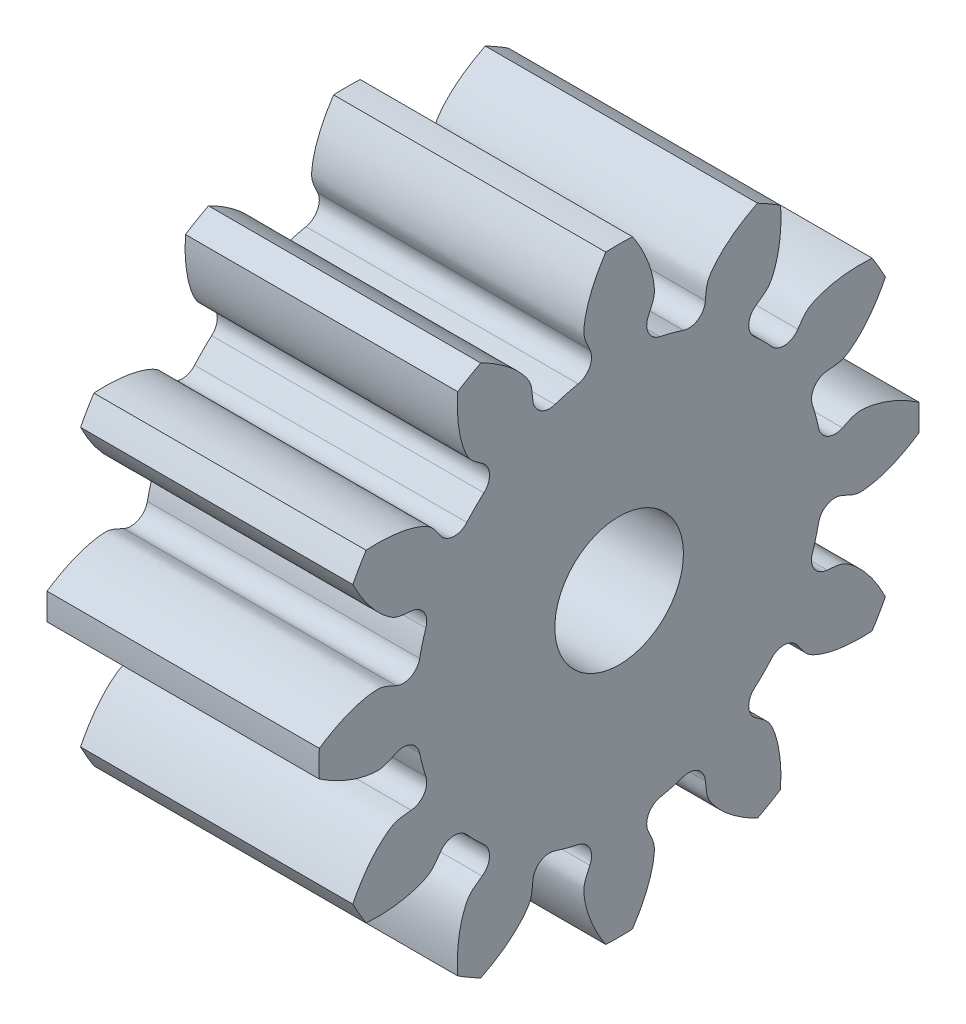
from build123d import *

# Parameters (mm, degrees)
EXTRUDE1_DEPTH      = 3.175
EXTRUDE1_DEPTH_BACK = 3.175
SKETCH2_R           = 1.5
CUT_EXTRUDE1_DEPTH  = 6.35


with BuildPart() as part:
    # Sketch1 → Extrude1 (new body, two sides)
    with BuildSketch(Plane(origin=(0, 0, 0), x_dir=(0, 0, -1), z_dir=(1, 0, 0))) as extrude1_sk:
        with BuildLine():
            ThreePointArc((-0.310347402, -6.993116937), (0, -7), (0.310347402, -6.993116937))
            add(Edge.make_bspline(
                [(0.310347402, -6.993116937), (0.332454088, -6.960100751), (0.397086112, -6.860495296), (0.507596749, -6.672467535), (0.626125065, -6.431893946), (0.720246921, -6.186920197), (0.779000049, -5.979736241), (0.809954136, -5.81518889), (0.821047695, -5.703074132), (0.822305692, -5.636998123), (0.821610044, -5.605303583), (0.814736989, -5.520886657), (0.783208617, -5.41000535), (0.683474653, -5.206966814)],
                knots=[0.012881598, 0.012881598, 0.012881598, 0.012881598, 0.092763794, 0.252528185, 0.452803648, 0.613451009, 0.736634468, 0.825277424, 0.882733012, 0.901221839, 0.913572897, 0.922587449, 0.997832853, 0.997832853, 0.997832853, 0.997832853], degree=3, weights=[1, 1, 1, 1, 1, 1, 1, 1, 1, 1, 1, 1, 1, 1]))
            ThreePointArc((0.683474653, -5.206966814), (0.6833523, -4.863322946), (0.955104633, -4.652985616))
            ThreePointArc((0.955104633, -4.652985616), (1.229390464, -4.588147675), (1.499347932, -4.507156063))
            ThreePointArc((1.499347932, -4.507156063), (1.839861021, -4.553437368), (2.011576994, -4.851102864))
            add(Edge.make_bspline(
                [(2.011576994, -4.851102864), (2.026724117, -5.076806376), (2.054860398, -5.188596591), (2.091116621, -5.265140321), (2.106361443, -5.292936422), (2.140488904, -5.349530925), (2.206153588, -5.441078375), (2.315234289, -5.568103517), (2.469707968, -5.718153522), (2.67370676, -5.883246084), (2.896642088, -6.032324766), (3.086360987, -6.139906265), (3.19213669, -6.193851107), (3.227789734, -6.21139062)],
                knots=[0.002100409, 0.002100409, 0.002100409, 0.002100409, 0.077349591, 0.086364597, 0.098716275, 0.11720603, 0.174664504, 0.263311911, 0.386501556, 0.547156985, 0.747442506, 0.90721492, 0.987101128, 0.987101128, 0.987101128, 0.987101128], degree=3, weights=[1, 1, 1, 1, 1, 1, 1, 1, 1, 1, 1, 1, 1, 1]))
            ThreePointArc((3.227789734, -6.21139062), (3.5, -6.062177826), (3.765327202, -5.901043218))
            add(Edge.make_bspline(
                [(3.765327202, -5.901043218), (3.767964061, -5.861397019), (3.774134309, -5.742820152), (3.775825447, -5.524728017), (3.758187185, -5.257121019), (3.717212229, -4.997906601), (3.664501952, -4.789103468), (3.609035303, -4.631124239), (3.562585227, -4.52848323), (3.530636681, -4.47063073), (3.514186962, -4.443530277), (3.466026259, -4.373859602), (3.383281234, -4.293597759), (3.195389819, -4.167628211)],
                knots=[0.012881598, 0.012881598, 0.012881598, 0.012881598, 0.092763794, 0.252528185, 0.452803648, 0.613451009, 0.736634468, 0.825277424, 0.882733012, 0.901221839, 0.913572897, 0.922587449, 0.997832853, 0.997832853, 0.997832853, 0.997832853], degree=3, weights=[1, 1, 1, 1, 1, 1, 1, 1, 1, 1, 1, 1, 1, 1]))
            ThreePointArc((3.195389819, -4.167628211), (3.023461924, -3.870085068), (3.153637683, -3.55205143))
            ThreePointArc((3.153637683, -3.55205143), (3.358757211, -3.358757211), (3.55205143, -3.153637683))
            ThreePointArc((3.55205143, -3.153637683), (3.870085068, -3.023461924), (4.167628211, -3.195389819))
            add(Edge.make_bspline(
                [(4.167628211, -3.195389819), (4.293597759, -3.383281234), (4.373859602, -3.466026259), (4.443530277, -3.514186962), (4.47063073, -3.530636681), (4.52848323, -3.562585227), (4.631124239, -3.609035303), (4.789103468, -3.664501952), (4.997906601, -3.717212229), (5.257121019, -3.758187185), (5.524728017, -3.775825447), (5.742820152, -3.774134309), (5.861397019, -3.767964061), (5.901043218, -3.765327202)],
                knots=[0.002100409, 0.002100409, 0.002100409, 0.002100409, 0.077349591, 0.086364597, 0.098716275, 0.11720603, 0.174664504, 0.263311911, 0.386501556, 0.547156985, 0.747442506, 0.90721492, 0.987101128, 0.987101128, 0.987101128, 0.987101128], degree=3, weights=[1, 1, 1, 1, 1, 1, 1, 1, 1, 1, 1, 1, 1, 1]))
            ThreePointArc((5.901043218, -3.765327202), (6.062177826, -3.5), (6.21139062, -3.227789734))
            add(Edge.make_bspline(
                [(6.21139062, -3.227789734), (6.193851107, -3.19213669), (6.139906265, -3.086360987), (6.032324766, -2.896642088), (5.883246084, -2.67370676), (5.718153522, -2.469707968), (5.568103517, -2.315234289), (5.441078375, -2.206153588), (5.349530925, -2.140488904), (5.292936422, -2.106361443), (5.265140321, -2.091116621), (5.188596591, -2.054860398), (5.076806376, -2.026724117), (4.851102864, -2.011576994)],
                knots=[0.012881598, 0.012881598, 0.012881598, 0.012881598, 0.092763794, 0.252528185, 0.452803648, 0.613451009, 0.736634468, 0.825277424, 0.882733012, 0.901221839, 0.913572897, 0.922587449, 0.997832853, 0.997832853, 0.997832853, 0.997832853], degree=3, weights=[1, 1, 1, 1, 1, 1, 1, 1, 1, 1, 1, 1, 1, 1]))
            ThreePointArc((4.851102864, -2.011576994), (4.553437368, -1.839861021), (4.507156063, -1.499347932))
            ThreePointArc((4.507156063, -1.499347932), (4.588147675, -1.229390464), (4.652985616, -0.955104633))
            ThreePointArc((4.652985616, -0.955104633), (4.863322946, -0.6833523), (5.206966814, -0.683474653))
            add(Edge.make_bspline(
                [(5.206966814, -0.683474653), (5.41000535, -0.783208617), (5.520886657, -0.814736989), (5.605303583, -0.821610044), (5.636998123, -0.822305692), (5.703074132, -0.821047695), (5.81518889, -0.809954136), (5.979736241, -0.779000049), (6.186920197, -0.720246921), (6.431893946, -0.626125065), (6.672467535, -0.507596749), (6.860495296, -0.397086112), (6.960100751, -0.332454088), (6.993116937, -0.310347402)],
                knots=[0.002100409, 0.002100409, 0.002100409, 0.002100409, 0.077349591, 0.086364597, 0.098716275, 0.11720603, 0.174664504, 0.263311911, 0.386501556, 0.547156985, 0.747442506, 0.90721492, 0.987101128, 0.987101128, 0.987101128, 0.987101128], degree=3, weights=[1, 1, 1, 1, 1, 1, 1, 1, 1, 1, 1, 1, 1, 1]))
            ThreePointArc((6.993116937, -0.310347402), (7, 0), (6.993116937, 0.310347402))
            add(Edge.make_bspline(
                [(6.993116937, 0.310347402), (6.960100751, 0.332454088), (6.860495296, 0.397086112), (6.672467535, 0.507596749), (6.431893946, 0.626125065), (6.186920197, 0.720246921), (5.979736241, 0.779000049), (5.81518889, 0.809954136), (5.703074132, 0.821047695), (5.636998123, 0.822305692), (5.605303583, 0.821610044), (5.520886657, 0.814736989), (5.41000535, 0.783208617), (5.206966814, 0.683474653)],
                knots=[0.012881598, 0.012881598, 0.012881598, 0.012881598, 0.092763794, 0.252528185, 0.452803648, 0.613451009, 0.736634468, 0.825277424, 0.882733012, 0.901221839, 0.913572897, 0.922587449, 0.997832853, 0.997832853, 0.997832853, 0.997832853], degree=3, weights=[1, 1, 1, 1, 1, 1, 1, 1, 1, 1, 1, 1, 1, 1]))
            ThreePointArc((5.206966814, 0.683474653), (4.863322946, 0.6833523), (4.652985616, 0.955104633))
            ThreePointArc((4.652985616, 0.955104633), (4.588147675, 1.229390464), (4.507156063, 1.499347932))
            ThreePointArc((4.507156063, 1.499347932), (4.553437368, 1.839861021), (4.851102864, 2.011576994))
            add(Edge.make_bspline(
                [(4.851102864, 2.011576994), (5.076806376, 2.026724117), (5.188596591, 2.054860398), (5.265140321, 2.091116621), (5.292936422, 2.106361443), (5.349530925, 2.140488904), (5.441078375, 2.206153588), (5.568103517, 2.315234289), (5.718153522, 2.469707968), (5.883246084, 2.67370676), (6.032324766, 2.896642088), (6.139906265, 3.086360987), (6.193851107, 3.19213669), (6.21139062, 3.227789734)],
                knots=[0.002100409, 0.002100409, 0.002100409, 0.002100409, 0.077349591, 0.086364597, 0.098716275, 0.11720603, 0.174664504, 0.263311911, 0.386501556, 0.547156985, 0.747442506, 0.90721492, 0.987101128, 0.987101128, 0.987101128, 0.987101128], degree=3, weights=[1, 1, 1, 1, 1, 1, 1, 1, 1, 1, 1, 1, 1, 1]))
            ThreePointArc((6.21139062, 3.227789734), (6.062177826, 3.5), (5.901043218, 3.765327202))
            add(Edge.make_bspline(
                [(5.901043218, 3.765327202), (5.861397019, 3.767964061), (5.742820152, 3.774134309), (5.524728017, 3.775825447), (5.257121019, 3.758187185), (4.997906601, 3.717212229), (4.789103468, 3.664501952), (4.631124239, 3.609035303), (4.52848323, 3.562585227), (4.47063073, 3.530636681), (4.443530277, 3.514186962), (4.373859602, 3.466026259), (4.293597759, 3.383281234), (4.167628211, 3.195389819)],
                knots=[0.012881598, 0.012881598, 0.012881598, 0.012881598, 0.092763794, 0.252528185, 0.452803648, 0.613451009, 0.736634468, 0.825277424, 0.882733012, 0.901221839, 0.913572897, 0.922587449, 0.997832853, 0.997832853, 0.997832853, 0.997832853], degree=3, weights=[1, 1, 1, 1, 1, 1, 1, 1, 1, 1, 1, 1, 1, 1]))
            ThreePointArc((4.167628211, 3.195389819), (3.870085068, 3.023461924), (3.55205143, 3.153637683))
            ThreePointArc((3.55205143, 3.153637683), (3.358757211, 3.358757211), (3.153637683, 3.55205143))
            ThreePointArc((3.153637683, 3.55205143), (3.023461924, 3.870085068), (3.195389819, 4.167628211))
            add(Edge.make_bspline(
                [(3.195389819, 4.167628211), (3.383281234, 4.293597759), (3.466026259, 4.373859602), (3.514186962, 4.443530277), (3.530636681, 4.47063073), (3.562585227, 4.52848323), (3.609035303, 4.631124239), (3.664501952, 4.789103468), (3.717212229, 4.997906601), (3.758187185, 5.257121019), (3.775825447, 5.524728017), (3.774134309, 5.742820152), (3.767964061, 5.861397019), (3.765327202, 5.901043218)],
                knots=[0.002100409, 0.002100409, 0.002100409, 0.002100409, 0.077349591, 0.086364597, 0.098716275, 0.11720603, 0.174664504, 0.263311911, 0.386501556, 0.547156985, 0.747442506, 0.90721492, 0.987101128, 0.987101128, 0.987101128, 0.987101128], degree=3, weights=[1, 1, 1, 1, 1, 1, 1, 1, 1, 1, 1, 1, 1, 1]))
            ThreePointArc((3.765327202, 5.901043218), (3.5, 6.062177826), (3.227789734, 6.21139062))
            add(Edge.make_bspline(
                [(3.227789734, 6.21139062), (3.19213669, 6.193851107), (3.086360987, 6.139906265), (2.896642088, 6.032324766), (2.67370676, 5.883246084), (2.469707968, 5.718153522), (2.315234289, 5.568103517), (2.206153588, 5.441078375), (2.140488904, 5.349530925), (2.106361443, 5.292936422), (2.091116621, 5.265140321), (2.054860398, 5.188596591), (2.026724117, 5.076806376), (2.011576994, 4.851102864)],
                knots=[0.012881598, 0.012881598, 0.012881598, 0.012881598, 0.092763794, 0.252528185, 0.452803648, 0.613451009, 0.736634468, 0.825277424, 0.882733012, 0.901221839, 0.913572897, 0.922587449, 0.997832853, 0.997832853, 0.997832853, 0.997832853], degree=3, weights=[1, 1, 1, 1, 1, 1, 1, 1, 1, 1, 1, 1, 1, 1]))
            ThreePointArc((2.011576994, 4.851102864), (1.839861021, 4.553437368), (1.499347932, 4.507156063))
            ThreePointArc((1.499347932, 4.507156063), (1.229390464, 4.588147675), (0.955104633, 4.652985616))
            ThreePointArc((0.955104633, 4.652985616), (0.6833523, 4.863322946), (0.683474653, 5.206966814))
            add(Edge.make_bspline(
                [(0.683474653, 5.206966814), (0.783208617, 5.41000535), (0.814736989, 5.520886657), (0.821610044, 5.605303583), (0.822305692, 5.636998123), (0.821047695, 5.703074132), (0.809954136, 5.81518889), (0.779000049, 5.979736241), (0.720246921, 6.186920197), (0.626125065, 6.431893946), (0.507596749, 6.672467535), (0.397086112, 6.860495296), (0.332454088, 6.960100751), (0.310347402, 6.993116937)],
                knots=[0.002100409, 0.002100409, 0.002100409, 0.002100409, 0.077349591, 0.086364597, 0.098716275, 0.11720603, 0.174664504, 0.263311911, 0.386501556, 0.547156985, 0.747442506, 0.90721492, 0.987101128, 0.987101128, 0.987101128, 0.987101128], degree=3, weights=[1, 1, 1, 1, 1, 1, 1, 1, 1, 1, 1, 1, 1, 1]))
            ThreePointArc((0.310347402, 6.993116937), (0, 7), (-0.310347402, 6.993116937))
            add(Edge.make_bspline(
                [(-0.310347402, 6.993116937), (-0.332454088, 6.960100751), (-0.397086112, 6.860495296), (-0.507596749, 6.672467535), (-0.626125065, 6.431893946), (-0.720246921, 6.186920197), (-0.779000049, 5.979736241), (-0.809954136, 5.81518889), (-0.821047695, 5.703074132), (-0.822305692, 5.636998123), (-0.821610044, 5.605303583), (-0.814736989, 5.520886657), (-0.783208617, 5.41000535), (-0.683474653, 5.206966814)],
                knots=[0.012881598, 0.012881598, 0.012881598, 0.012881598, 0.092763794, 0.252528185, 0.452803648, 0.613451009, 0.736634468, 0.825277424, 0.882733012, 0.901221839, 0.913572897, 0.922587449, 0.997832853, 0.997832853, 0.997832853, 0.997832853], degree=3, weights=[1, 1, 1, 1, 1, 1, 1, 1, 1, 1, 1, 1, 1, 1]))
            ThreePointArc((-0.683474653, 5.206966814), (-0.6833523, 4.863322946), (-0.955104633, 4.652985616))
            ThreePointArc((-0.955104633, 4.652985616), (-1.229390464, 4.588147675), (-1.499347932, 4.507156063))
            ThreePointArc((-1.499347932, 4.507156063), (-1.839861021, 4.553437368), (-2.011576994, 4.851102864))
            add(Edge.make_bspline(
                [(-2.011576994, 4.851102864), (-2.026724117, 5.076806376), (-2.054860398, 5.188596591), (-2.091116621, 5.265140321), (-2.106361443, 5.292936422), (-2.140488904, 5.349530925), (-2.206153588, 5.441078375), (-2.315234289, 5.568103517), (-2.469707968, 5.718153522), (-2.67370676, 5.883246084), (-2.896642088, 6.032324766), (-3.086360987, 6.139906265), (-3.19213669, 6.193851107), (-3.227789734, 6.21139062)],
                knots=[0.002100409, 0.002100409, 0.002100409, 0.002100409, 0.077349591, 0.086364597, 0.098716275, 0.11720603, 0.174664504, 0.263311911, 0.386501556, 0.547156985, 0.747442506, 0.90721492, 0.987101128, 0.987101128, 0.987101128, 0.987101128], degree=3, weights=[1, 1, 1, 1, 1, 1, 1, 1, 1, 1, 1, 1, 1, 1]))
            ThreePointArc((-3.227789734, 6.21139062), (-3.5, 6.062177826), (-3.765327202, 5.901043218))
            add(Edge.make_bspline(
                [(-3.765327202, 5.901043218), (-3.767964061, 5.861397019), (-3.774134309, 5.742820152), (-3.775825447, 5.524728017), (-3.758187185, 5.257121019), (-3.717212229, 4.997906601), (-3.664501952, 4.789103468), (-3.609035303, 4.631124239), (-3.562585227, 4.52848323), (-3.530636681, 4.47063073), (-3.514186962, 4.443530277), (-3.466026259, 4.373859602), (-3.383281234, 4.293597759), (-3.195389819, 4.167628211)],
                knots=[0.012881598, 0.012881598, 0.012881598, 0.012881598, 0.092763794, 0.252528185, 0.452803648, 0.613451009, 0.736634468, 0.825277424, 0.882733012, 0.901221839, 0.913572897, 0.922587449, 0.997832853, 0.997832853, 0.997832853, 0.997832853], degree=3, weights=[1, 1, 1, 1, 1, 1, 1, 1, 1, 1, 1, 1, 1, 1]))
            ThreePointArc((-3.195389819, 4.167628211), (-3.023461924, 3.870085068), (-3.153637683, 3.55205143))
            ThreePointArc((-3.153637683, 3.55205143), (-3.358757211, 3.358757211), (-3.55205143, 3.153637683))
            ThreePointArc((-3.55205143, 3.153637683), (-3.870085068, 3.023461924), (-4.167628211, 3.195389819))
            add(Edge.make_bspline(
                [(-4.167628211, 3.195389819), (-4.293597759, 3.383281234), (-4.373859602, 3.466026259), (-4.443530277, 3.514186962), (-4.47063073, 3.530636681), (-4.52848323, 3.562585227), (-4.631124239, 3.609035303), (-4.789103468, 3.664501952), (-4.997906601, 3.717212229), (-5.257121019, 3.758187185), (-5.524728017, 3.775825447), (-5.742820152, 3.774134309), (-5.861397019, 3.767964061), (-5.901043218, 3.765327202)],
                knots=[0.002100409, 0.002100409, 0.002100409, 0.002100409, 0.077349591, 0.086364597, 0.098716275, 0.11720603, 0.174664504, 0.263311911, 0.386501556, 0.547156985, 0.747442506, 0.90721492, 0.987101128, 0.987101128, 0.987101128, 0.987101128], degree=3, weights=[1, 1, 1, 1, 1, 1, 1, 1, 1, 1, 1, 1, 1, 1]))
            ThreePointArc((-5.901043218, 3.765327202), (-6.062177826, 3.5), (-6.21139062, 3.227789734))
            add(Edge.make_bspline(
                [(-6.21139062, 3.227789734), (-6.193851107, 3.19213669), (-6.139906265, 3.086360987), (-6.032324766, 2.896642088), (-5.883246084, 2.67370676), (-5.718153522, 2.469707968), (-5.568103517, 2.315234289), (-5.441078375, 2.206153588), (-5.349530925, 2.140488904), (-5.292936422, 2.106361443), (-5.265140321, 2.091116621), (-5.188596591, 2.054860398), (-5.076806376, 2.026724117), (-4.851102864, 2.011576994)],
                knots=[0.012881598, 0.012881598, 0.012881598, 0.012881598, 0.092763794, 0.252528185, 0.452803648, 0.613451009, 0.736634468, 0.825277424, 0.882733012, 0.901221839, 0.913572897, 0.922587449, 0.997832853, 0.997832853, 0.997832853, 0.997832853], degree=3, weights=[1, 1, 1, 1, 1, 1, 1, 1, 1, 1, 1, 1, 1, 1]))
            ThreePointArc((-4.851102864, 2.011576994), (-4.553437368, 1.839861021), (-4.507156063, 1.499347932))
            ThreePointArc((-4.507156063, 1.499347932), (-4.588147675, 1.229390464), (-4.652985616, 0.955104633))
            ThreePointArc((-4.652985616, 0.955104633), (-4.863322946, 0.6833523), (-5.206966814, 0.683474653))
            add(Edge.make_bspline(
                [(-5.206966814, 0.683474653), (-5.41000535, 0.783208617), (-5.520886657, 0.814736989), (-5.605303583, 0.821610044), (-5.636998123, 0.822305692), (-5.703074132, 0.821047695), (-5.81518889, 0.809954136), (-5.979736241, 0.779000049), (-6.186920197, 0.720246921), (-6.431893946, 0.626125065), (-6.672467535, 0.507596749), (-6.860495296, 0.397086112), (-6.960100751, 0.332454088), (-6.993116937, 0.310347402)],
                knots=[0.002100409, 0.002100409, 0.002100409, 0.002100409, 0.077349591, 0.086364597, 0.098716275, 0.11720603, 0.174664504, 0.263311911, 0.386501556, 0.547156985, 0.747442506, 0.90721492, 0.987101128, 0.987101128, 0.987101128, 0.987101128], degree=3, weights=[1, 1, 1, 1, 1, 1, 1, 1, 1, 1, 1, 1, 1, 1]))
            ThreePointArc((-6.993116937, 0.310347402), (-7, 0), (-6.993116937, -0.310347402))
            add(Edge.make_bspline(
                [(-6.993116937, -0.310347402), (-6.960100751, -0.332454088), (-6.860495296, -0.397086112), (-6.672467535, -0.507596749), (-6.431893946, -0.626125065), (-6.186920197, -0.720246921), (-5.979736241, -0.779000049), (-5.81518889, -0.809954136), (-5.703074132, -0.821047695), (-5.636998123, -0.822305692), (-5.605303583, -0.821610044), (-5.520886657, -0.814736989), (-5.41000535, -0.783208617), (-5.206966814, -0.683474653)],
                knots=[0.012881598, 0.012881598, 0.012881598, 0.012881598, 0.092763794, 0.252528185, 0.452803648, 0.613451009, 0.736634468, 0.825277424, 0.882733012, 0.901221839, 0.913572897, 0.922587449, 0.997832853, 0.997832853, 0.997832853, 0.997832853], degree=3, weights=[1, 1, 1, 1, 1, 1, 1, 1, 1, 1, 1, 1, 1, 1]))
            ThreePointArc((-5.206966814, -0.683474653), (-4.863322946, -0.6833523), (-4.652985616, -0.955104633))
            ThreePointArc((-4.652985616, -0.955104633), (-4.588147675, -1.229390464), (-4.507156063, -1.499347932))
            ThreePointArc((-4.507156063, -1.499347932), (-4.553437368, -1.839861021), (-4.851102864, -2.011576994))
            add(Edge.make_bspline(
                [(-4.851102864, -2.011576994), (-5.076806376, -2.026724117), (-5.188596591, -2.054860398), (-5.265140321, -2.091116621), (-5.292936422, -2.106361443), (-5.349530925, -2.140488904), (-5.441078375, -2.206153588), (-5.568103517, -2.315234289), (-5.718153522, -2.469707968), (-5.883246084, -2.67370676), (-6.032324766, -2.896642088), (-6.139906265, -3.086360987), (-6.193851107, -3.19213669), (-6.21139062, -3.227789734)],
                knots=[0.002100409, 0.002100409, 0.002100409, 0.002100409, 0.077349591, 0.086364597, 0.098716275, 0.11720603, 0.174664504, 0.263311911, 0.386501556, 0.547156985, 0.747442506, 0.90721492, 0.987101128, 0.987101128, 0.987101128, 0.987101128], degree=3, weights=[1, 1, 1, 1, 1, 1, 1, 1, 1, 1, 1, 1, 1, 1]))
            ThreePointArc((-6.21139062, -3.227789734), (-6.062177826, -3.5), (-5.901043218, -3.765327202))
            add(Edge.make_bspline(
                [(-5.901043218, -3.765327202), (-5.861397019, -3.767964061), (-5.742820152, -3.774134309), (-5.524728017, -3.775825447), (-5.257121019, -3.758187185), (-4.997906601, -3.717212229), (-4.789103468, -3.664501952), (-4.631124239, -3.609035303), (-4.52848323, -3.562585227), (-4.47063073, -3.530636681), (-4.443530277, -3.514186962), (-4.373859602, -3.466026259), (-4.293597759, -3.383281234), (-4.167628211, -3.195389819)],
                knots=[0.012881598, 0.012881598, 0.012881598, 0.012881598, 0.092763794, 0.252528185, 0.452803648, 0.613451009, 0.736634468, 0.825277424, 0.882733012, 0.901221839, 0.913572897, 0.922587449, 0.997832853, 0.997832853, 0.997832853, 0.997832853], degree=3, weights=[1, 1, 1, 1, 1, 1, 1, 1, 1, 1, 1, 1, 1, 1]))
            ThreePointArc((-4.167628211, -3.195389819), (-3.870085068, -3.023461924), (-3.55205143, -3.153637683))
            ThreePointArc((-3.55205143, -3.153637683), (-3.358757211, -3.358757211), (-3.153637683, -3.55205143))
            ThreePointArc((-3.153637683, -3.55205143), (-3.023461924, -3.870085068), (-3.195389819, -4.167628211))
            add(Edge.make_bspline(
                [(-3.195389819, -4.167628211), (-3.383281234, -4.293597759), (-3.466026259, -4.373859602), (-3.514186962, -4.443530277), (-3.530636681, -4.47063073), (-3.562585227, -4.52848323), (-3.609035303, -4.631124239), (-3.664501952, -4.789103468), (-3.717212229, -4.997906601), (-3.758187185, -5.257121019), (-3.775825447, -5.524728017), (-3.774134309, -5.742820152), (-3.767964061, -5.861397019), (-3.765327202, -5.901043218)],
                knots=[0.002100409, 0.002100409, 0.002100409, 0.002100409, 0.077349591, 0.086364597, 0.098716275, 0.11720603, 0.174664504, 0.263311911, 0.386501556, 0.547156985, 0.747442506, 0.90721492, 0.987101128, 0.987101128, 0.987101128, 0.987101128], degree=3, weights=[1, 1, 1, 1, 1, 1, 1, 1, 1, 1, 1, 1, 1, 1]))
            ThreePointArc((-3.765327202, -5.901043218), (-3.5, -6.062177826), (-3.227789734, -6.21139062))
            add(Edge.make_bspline(
                [(-3.227789734, -6.21139062), (-3.19213669, -6.193851107), (-3.086360987, -6.139906265), (-2.896642088, -6.032324766), (-2.67370676, -5.883246084), (-2.469707968, -5.718153522), (-2.315234289, -5.568103517), (-2.206153588, -5.441078375), (-2.140488904, -5.349530925), (-2.106361443, -5.292936422), (-2.091116621, -5.265140321), (-2.054860398, -5.188596591), (-2.026724117, -5.076806376), (-2.011576994, -4.851102864)],
                knots=[0.012881598, 0.012881598, 0.012881598, 0.012881598, 0.092763794, 0.252528185, 0.452803648, 0.613451009, 0.736634468, 0.825277424, 0.882733012, 0.901221839, 0.913572897, 0.922587449, 0.997832853, 0.997832853, 0.997832853, 0.997832853], degree=3, weights=[1, 1, 1, 1, 1, 1, 1, 1, 1, 1, 1, 1, 1, 1]))
            ThreePointArc((-2.011576994, -4.851102864), (-1.839861021, -4.553437368), (-1.499347932, -4.507156063))
            ThreePointArc((-1.499347932, -4.507156063), (-1.229390464, -4.588147675), (-0.955104633, -4.652985616))
            ThreePointArc((-0.955104633, -4.652985616), (-0.6833523, -4.863322946), (-0.683474653, -5.206966814))
            add(Edge.make_bspline(
                [(-0.683474653, -5.206966814), (-0.783208617, -5.41000535), (-0.814736989, -5.520886657), (-0.821610044, -5.605303583), (-0.822305692, -5.636998123), (-0.821047695, -5.703074132), (-0.809954136, -5.81518889), (-0.779000049, -5.979736241), (-0.720246921, -6.186920197), (-0.626125065, -6.431893946), (-0.507596749, -6.672467535), (-0.397086112, -6.860495296), (-0.332454088, -6.960100751), (-0.310347402, -6.993116937)],
                knots=[0.002100409, 0.002100409, 0.002100409, 0.002100409, 0.077349591, 0.086364597, 0.098716275, 0.11720603, 0.174664504, 0.263311911, 0.386501556, 0.547156985, 0.747442506, 0.90721492, 0.987101128, 0.987101128, 0.987101128, 0.987101128], degree=3, weights=[1, 1, 1, 1, 1, 1, 1, 1, 1, 1, 1, 1, 1, 1]))
        make_face()
    extrude(amount=EXTRUDE1_DEPTH)
    extrude(extrude1_sk.sketch, amount=-EXTRUDE1_DEPTH_BACK)

    # Sketch2 → Cut-Extrude1 (cut)
    with BuildSketch(Plane(origin=(3.175, 0, 0), x_dir=(0, 0, -1), z_dir=(1, 0, 0))):
        Circle(SKETCH2_R)
    extrude(amount=-CUT_EXTRUDE1_DEPTH, mode=Mode.SUBTRACT)


solid = part.part
